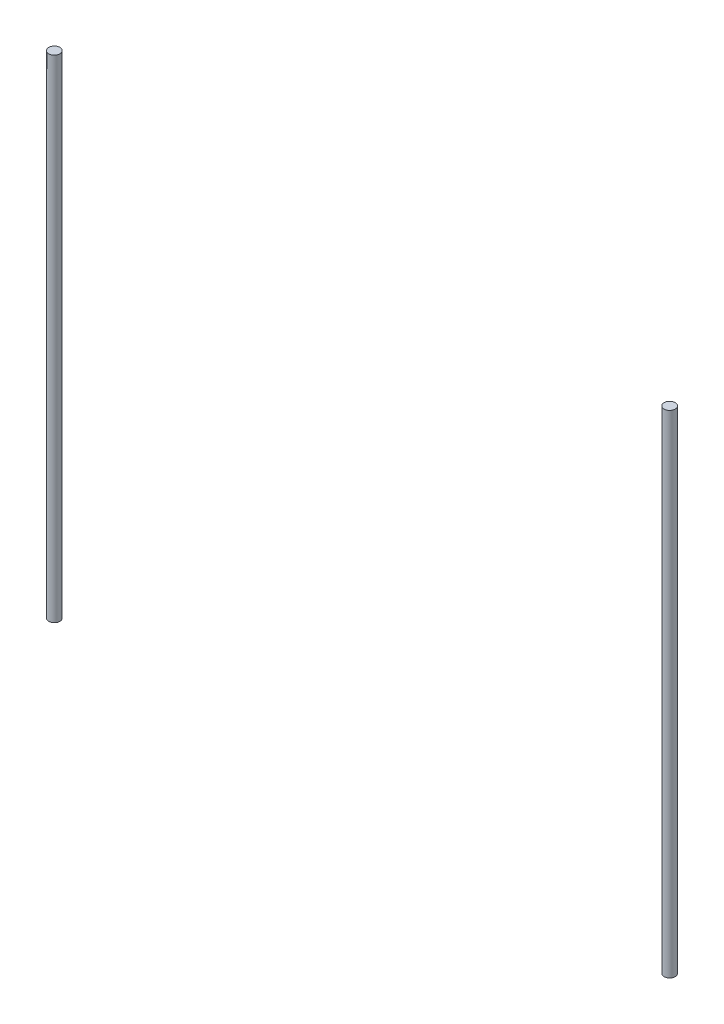
from build123d import *

# Parameters (mm, degrees)
SKETCH1_R             = 4
BOSS_EXTRUDE1_DEPTH   = 351.5
BOSS_EXTRUDE1_2_DEPTH = 351.5


with BuildPart() as part:
    # Sketch1 → Boss-Extrude1 (new body)
    with BuildSketch(Plane(origin=(0, 0, 0), x_dir=(1, 0, 0), z_dir=(0, 1, 0))):
        with Locations((-220, 0)):
            Circle(SKETCH1_R)
    extrude(amount=BOSS_EXTRUDE1_DEPTH)


with BuildPart() as body_2:
    # Sketch1 → Boss-Extrude1 2 (new body)
    with BuildSketch(Plane(origin=(0, 0, 0), x_dir=(1, 0, 0), z_dir=(0, 1, 0))):
        with Locations((220, 0)):
            Circle(SKETCH1_R)
    extrude(amount=BOSS_EXTRUDE1_2_DEPTH)


solid = Compound([part.part, body_2.part])
